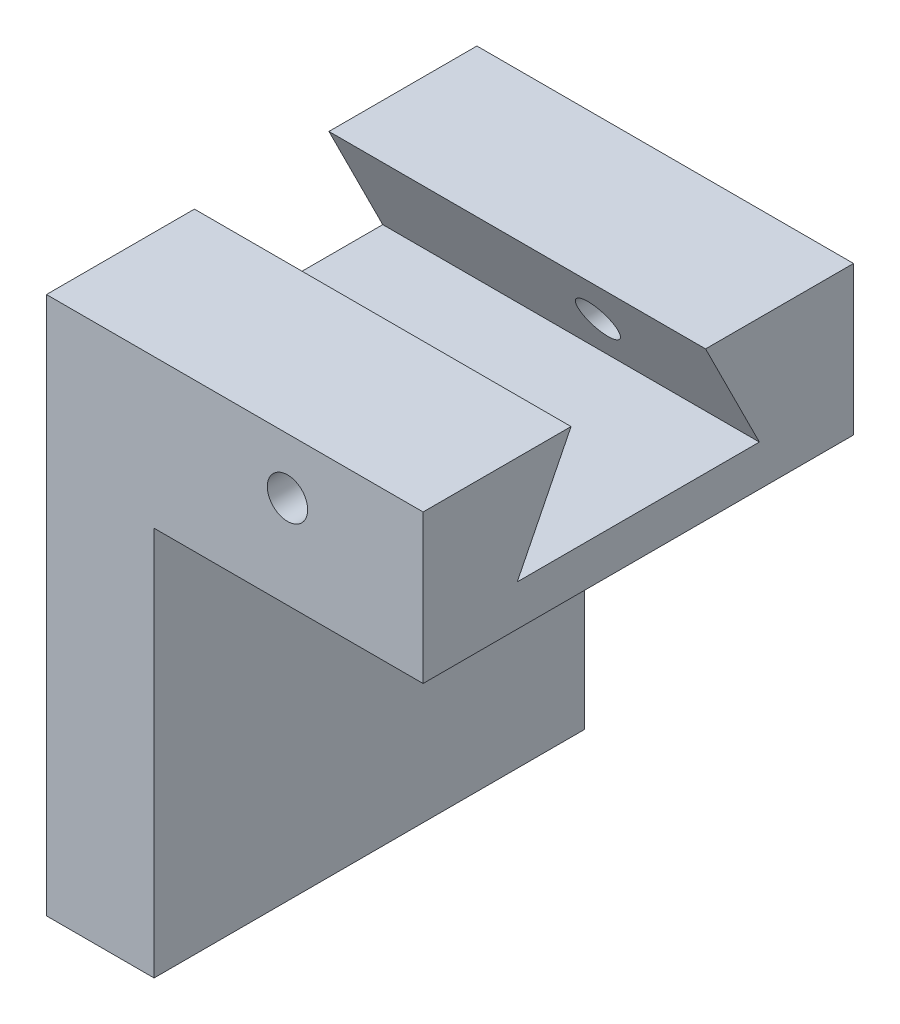
from build123d import *

# Parameters (mm, degrees)
SKETCH1_W           = 19
SKETCH1_H           = 9
BOSS_EXTRUDE1_DEPTH = 4
CUT_EXTRUDE1_REACH  = 10
SKETCH2_W           = 15
SKETCH2_H           = 7
CUT_EXTRUDE3_REACH  = 10
SKETCH5_W           = 2
SKETCH5_H           = 9
BOSS_EXTRUDE2_DEPTH = 5
CUT_EXTRUDE4_REACH  = 19
SKETCH7_W           = 8
SKETCH7_H           = 2
SKETCH8_R           = 0.375
CUT_EXTRUDE6_DEPTH  = 8
SKETCH9_W           = 2
SKETCH9_H           = 7.24
BOSS_EXTRUDE3_DEPTH = 8
CUT_EXTRUDE7_REACH  = 4


with BuildPart() as part:
    # Sketch1 → Boss-Extrude1 (new body, symmetric)
    with BuildSketch(Plane.XY):
        Rectangle(SKETCH1_W, SKETCH1_H)
    extrude(amount=BOSS_EXTRUDE1_DEPTH, both=True)

    # Sketch2 → Cut-Extrude1 (cut, up to next)
    with BuildSketch(Plane.XY.offset(4), mode=Mode.PRIVATE) as cut_extrude1_sk1:
        with Locations((0, -1)):
            Rectangle(SKETCH2_W, SKETCH2_H)
    cut_extrude1_tool1 = extrude(cut_extrude1_sk1.sketch, amount=-CUT_EXTRUDE1_REACH, mode=Mode.PRIVATE) & part.part
    add(cut_extrude1_tool1.solids().sort_by_distance((0, -1, 4))[0], mode=Mode.SUBTRACT)

    # Sketch5 → Cut-Extrude3 (cut, up to next)
    with BuildSketch(Plane.XY.offset(4), mode=Mode.PRIVATE) as cut_extrude3_sk1:
        with Locations((8.5, 0)):
            Rectangle(SKETCH5_W, SKETCH5_H)
    cut_extrude3_tool1 = extrude(cut_extrude3_sk1.sketch, amount=-CUT_EXTRUDE3_REACH, mode=Mode.PRIVATE) & part.part
    add(cut_extrude3_tool1.solids().sort_by_distance((8.5, 0, 4))[0], mode=Mode.SUBTRACT)

    # Sketch6 → Boss-Extrude2 (add)
    with BuildSketch(Plane(origin=(-7.5, 0, 0), x_dir=(0, 0, -1), z_dir=(1, 0, 0))):
        Polygon((4, 2.5), (1.25, 2.5), (2, 0.999999988), (2.249999998, 0.499999988), (-2.249999998, 0.499999988), (-2, 0.999999988), (-1.25, 2.5), (-4, 2.5), (-4, -0.260952874), (4, -0.260952874), align=None)
    extrude(amount=BOSS_EXTRUDE2_DEPTH)

    # Sketch7 → Cut-Extrude4 (cut, up to next)
    with BuildSketch(Plane(origin=(7.5, 0, 0), x_dir=(0, 0, -1), z_dir=(1, 0, 0)), mode=Mode.PRIVATE) as cut_extrude4_sk1:
        with Locations((0, 3.5)):
            Rectangle(SKETCH7_W, SKETCH7_H)
    cut_extrude4_tool1 = extrude(cut_extrude4_sk1.sketch, amount=-CUT_EXTRUDE4_REACH, mode=Mode.PRIVATE) & part.part
    add(cut_extrude4_tool1.solids().sort_by_distance((7.5, 3.5, 0))[0], mode=Mode.SUBTRACT)

    # Sketch8 → Cut-Extrude6 (cut)
    with BuildSketch(Plane(origin=(0, 0, -4), x_dir=(-1, 0, 0), z_dir=(0, 0, -1))):
        with Locations((5.019927309, 1.462821702)):
            Circle(SKETCH8_R)
    extrude(amount=-CUT_EXTRUDE6_DEPTH, mode=Mode.SUBTRACT)

    # Sketch9 → Boss-Extrude3 (add)
    with BuildSketch(Plane(origin=(0, 0, -4), x_dir=(-1, 0, 0), z_dir=(0, 0, -1))):
        with Locations((8.5, -3.880952874)):
            Rectangle(SKETCH9_W, SKETCH9_H)
    extrude(amount=-BOSS_EXTRUDE3_DEPTH)

    # Sketch10 → Cut-Extrude7 (cut, up to next)
    with BuildSketch(Plane(origin=(-7.5, 0, 0), x_dir=(0, 0, -1), z_dir=(1, 0, 0)), mode=Mode.PRIVATE) as cut_extrude7_sk1:
        Polygon((-2.249999998, 0.499999988), (-1.25, 2.5), (1.25, 2.5), (2.249999998, 0.499999988), align=None)
    cut_extrude7_tool1 = extrude(cut_extrude7_sk1.sketch, amount=-CUT_EXTRUDE7_REACH, mode=Mode.PRIVATE) & part.part
    add(cut_extrude7_tool1.solids().sort_by_distance((-7.5, 1.404762, 0))[0], mode=Mode.SUBTRACT)


solid = part.part
